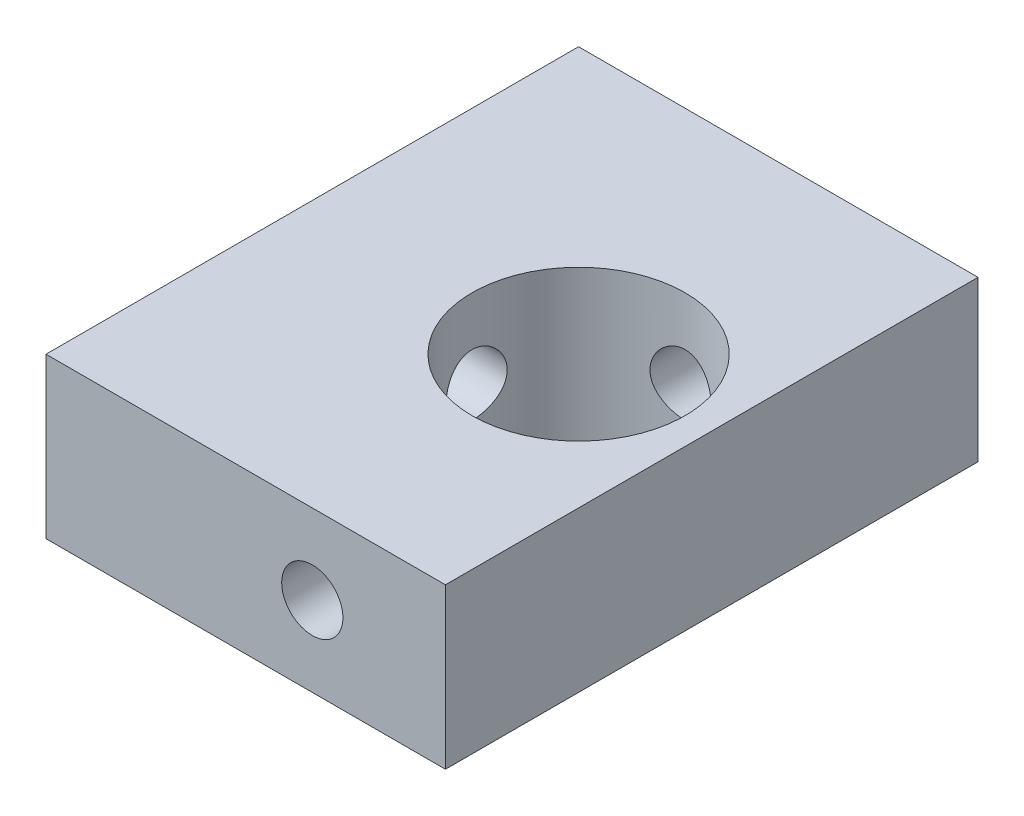
from build123d import *

# Parameters (mm, degrees)
SKETCH1_W           = 15
SKETCH1_H           = 6
SKETCH1_R           = 1.15
BOSS_EXTRUDE1_DEPTH = 20
SKETCH2_R           = 4
CUT_EXTRUDE2_DEPTH  = 20
CUT_EXTRUDE3_REACH  = 17
SKETCH4_R           = 1.15


with BuildPart() as part:
    # Sketch1 → Boss-Extrude1 (new body)
    with BuildSketch(Plane.XY):
        with Locations((7.5, 3)):
            Rectangle(SKETCH1_W, SKETCH1_H)
        with Locations((10, 3)):
            Circle(SKETCH1_R, mode=Mode.SUBTRACT)
    extrude(amount=BOSS_EXTRUDE1_DEPTH)

    # Sketch2 → Cut-Extrude2 (cut)
    with BuildSketch(Plane.XZ):
        with Locations((10, 10)):
            Circle(SKETCH2_R)
    extrude(amount=-CUT_EXTRUDE2_DEPTH, mode=Mode.SUBTRACT)

    # Sketch4 → Cut-Extrude3 (cut, up to next)
    with BuildSketch(Plane.ZY, mode=Mode.PRIVATE) as cut_extrude3_sk1:
        with Locations((10, 3)):
            Circle(SKETCH4_R)
    cut_extrude3_tool1 = extrude(cut_extrude3_sk1.sketch, amount=-CUT_EXTRUDE3_REACH, mode=Mode.PRIVATE) & part.part
    add(cut_extrude3_tool1.solids().sort_by_distance((0, 3, 10))[0], mode=Mode.SUBTRACT)


solid = part.part
